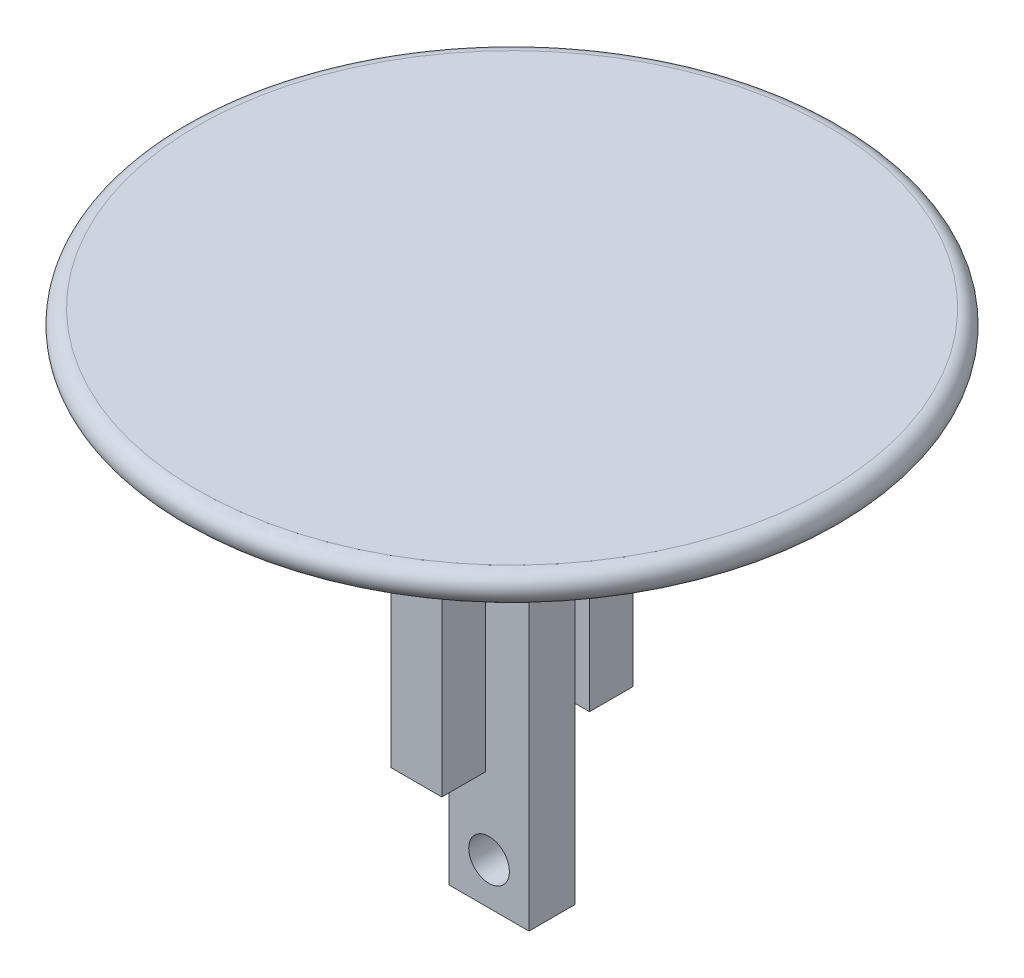
from build123d import *

# Parameters (mm, degrees)
SKETCH2_W           = 5.5
SKETCH2_H           = 3.17
BOSS_EXTRUDE1_DEPTH = 25
SKETCH3_R           = 1.4
CUT_EXTRUDE1_DEPTH  = 27.583939305
SKETCH6_W           = 3.5
SKETCH6_H           = 3
BOSS_EXTRUDE2_DEPTH = 15
FILLET2_R           = 1


with BuildPart() as part:
    # Sketch1 → Revolve1 (revolve)
    with BuildSketch(Plane.XY):
        Polygon((0, 0), (25, 0), (10, -10), (0, -10), align=None)
    revolve(axis=Axis((0, 0, 0), (0, -1, 0)))

    # Sketch2 → Boss-Extrude1 (add)
    with BuildSketch(Plane.XZ.offset(10)):
        with Locations((-0.00136169, 0.001060695)):
            Rectangle(SKETCH2_W, SKETCH2_H)
    extrude(amount=BOSS_EXTRUDE1_DEPTH)

    # Sketch3 → Cut-Extrude1 (cut, through all)
    with BuildSketch(Plane(origin=(0, 0, -1.583939305), x_dir=(-1, 0, 0), z_dir=(0, 0, -1))):
        with Locations((0, -32.128448622)):
            Circle(SKETCH3_R)
    extrude(amount=-CUT_EXTRUDE1_DEPTH, mode=Mode.SUBTRACT)

    # Sketch6 → Boss-Extrude2 (add)
    with BuildSketch(Plane.XZ.offset(10)):
        with Locations((-0.00136169, -5.083939305)):
            Rectangle(SKETCH6_W, SKETCH6_H)
        with Locations((-0.00136169, 5.086060695)):
            Rectangle(SKETCH6_W, SKETCH6_H)
    extrude(amount=BOSS_EXTRUDE2_DEPTH)

    # Fillet2
    fillet2_edges = [part.edges().sort_by_distance(p)[0] for p in [
        (-25, 0, 0),
    ]]
    fillet(fillet2_edges, radius=FILLET2_R)


solid = part.part
